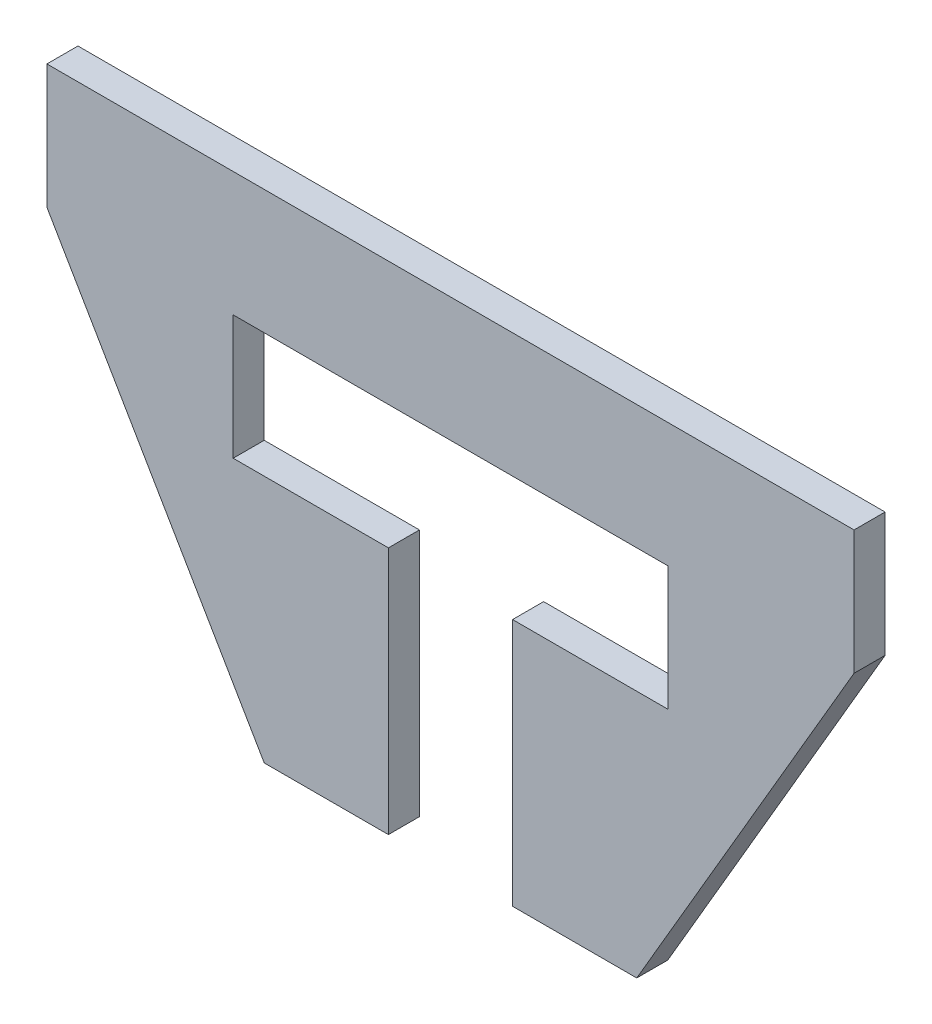
from build123d import *

# Parameters (mm, degrees)
BOSS_EXTRUDE1_DEPTH = 6.35


with BuildPart() as part:
    # Sketch1 → Boss-Extrude1 (new body)
    with BuildSketch(Plane.XY):
        Polygon((0, 0), (165.1, 0), (165.1, -25.4), (120.65, -101.6), (95.25, -101.6), (95.25, -50.8), (127, -50.8), (127, -25.4), (38.1, -25.4), (38.1, -50.8), (69.85, -50.8), (69.85, -101.6), (44.45, -101.6), (0, -25.4), align=None)
    extrude(amount=BOSS_EXTRUDE1_DEPTH)


solid = part.part
